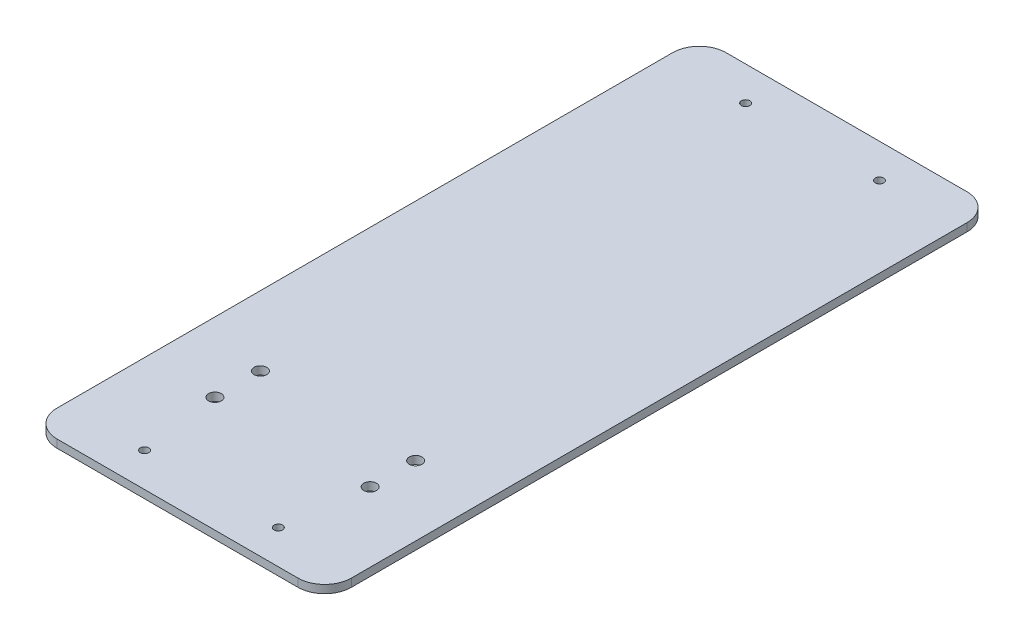
from build123d import *

# Parameters (mm, degrees)
SALIENTE_EXTRUIR1_DEPTH = 3
CROQUIS2_R              = 1.5875
CORTAR_EXTRUIR1_DEPTH   = 20
CROQUIS3_R              = 2.38125
CORTAR_EXTRUIR2_DEPTH   = 10


with BuildPart() as part:
    # Croquis1 → Saliente-Extruir1 (new body)
    with BuildSketch(Plane(origin=(0, 0, 0), x_dir=(1, 0, 0), z_dir=(0, 1, 0))):
        with BuildLine():
            Line((10, 0), (100, 0))
            ThreePointArc((100, 0), (107.071067812, 2.928932188), (110, 10))
            Line((110, 10), (110, 240))
            ThreePointArc((110, 240), (107.071067812, 247.071067812), (100, 250))
            Line((100, 250), (10, 250))
            ThreePointArc((10, 250), (2.928932188, 247.071067812), (0, 240))
            Line((0, 240), (0, 10))
            ThreePointArc((0, 10), (2.928932188, 2.928932188), (10, 0))
        make_face()
    extrude(amount=SALIENTE_EXTRUIR1_DEPTH)

    # Croquis2 → Cortar-Extruir1 (cut)
    with BuildSketch(Plane(origin=(0, 3, 0), x_dir=(1, 0, 0), z_dir=(0, 1, 0))):
        with Locations((30, 237.3)):
            Circle(CROQUIS2_R)
        with Locations((80, 237.3)):
            Circle(CROQUIS2_R)
        with Locations((30, 12.7)):
            Circle(CROQUIS2_R)
        with Locations((80, 12.7)):
            Circle(CROQUIS2_R)
    extrude(amount=-CORTAR_EXTRUIR1_DEPTH, mode=Mode.SUBTRACT)

    # Croquis3 → Cortar-Extruir2 (cut)
    with BuildSketch(Plane(origin=(0, 3, 0), x_dir=(1, 0, 0), z_dir=(0, 1, 0))):
        with Locations((26, 60)):
            Circle(CROQUIS3_R)
        with Locations((84, 60)):
            Circle(CROQUIS3_R)
        with Locations((26, 43)):
            Circle(CROQUIS3_R)
        with Locations((84, 43)):
            Circle(CROQUIS3_R)
    extrude(amount=-CORTAR_EXTRUIR2_DEPTH, mode=Mode.SUBTRACT)


solid = part.part
